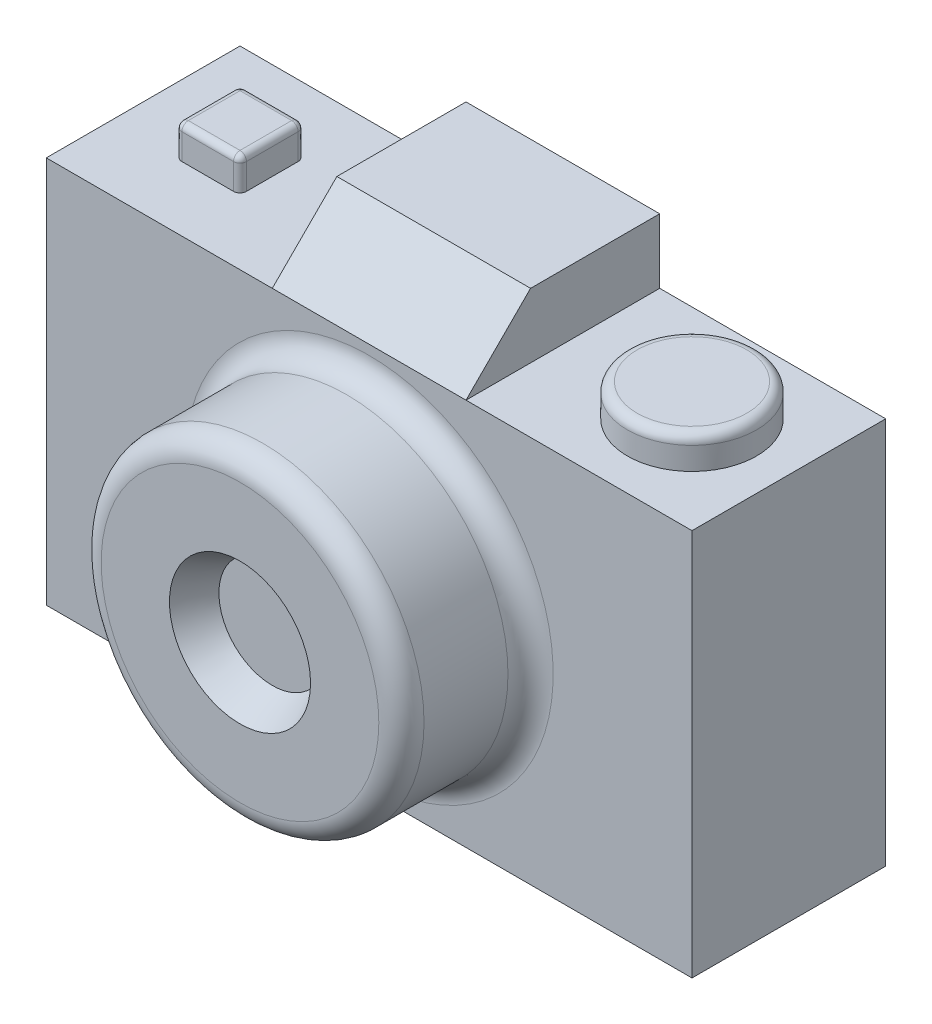
from build123d import *

# Parameters (mm, degrees)
SKETCH1_W           = 100
SKETCH1_H           = 30
BOSS_EXTRUDE1_DEPTH = 60
SKETCH2_R           = 25
BOSS_EXTRUDE2_DEPTH = 20
SKETCH3_R           = 10
SKETCH3_W           = 10
SKETCH3_H           = 10
BOSS_EXTRUDE3_DEPTH = 5
SKETCH4_W           = 30
SKETCH4_H           = 30
BOSS_EXTRUDE4_DEPTH = 10
CHAMFER1_SIZE       = 10
FILLET1_R           = 1
FILLET2_R           = 1.5
FILLET3_R           = 3.5
SKETCH5_R           = 10.925128043
CUT_EXTRUDE1_DEPTH  = 5
CUT_EXTRUDE1_TAPER  = 28


with BuildPart() as part:
    # Sketch1 → Boss-Extrude1 (new body)
    with BuildSketch(Plane(origin=(0, 0, 0), x_dir=(1, 0, 0), z_dir=(0, 1, 0))):
        with Locations((50, 15)):
            Rectangle(SKETCH1_W, SKETCH1_H)
    extrude(amount=BOSS_EXTRUDE1_DEPTH)

    # Sketch2 → Boss-Extrude2 (add)
    with BuildSketch(Plane.XY):
        with Locations((50, 30)):
            Circle(SKETCH2_R)
    extrude(amount=BOSS_EXTRUDE2_DEPTH)

    # Sketch3 → Boss-Extrude3 (add)
    with BuildSketch(Plane(origin=(0, 60, 0), x_dir=(1, 0, 0), z_dir=(0, 1, 0))):
        with Locations((85, 15)):
            Circle(SKETCH3_R)
        with Locations((15, 15)):
            Rectangle(SKETCH3_W, SKETCH3_H)
    extrude(amount=BOSS_EXTRUDE3_DEPTH)

    # Sketch4 → Boss-Extrude4 (add)
    with BuildSketch(Plane(origin=(0, 60, 0), x_dir=(1, 0, 0), z_dir=(0, 1, 0))):
        with Locations((50, 15)):
            Rectangle(SKETCH4_W, SKETCH4_H)
    extrude(amount=BOSS_EXTRUDE4_DEPTH)

    # Chamfer1
    chamfer1_edges = [part.edges().sort_by_distance(p)[0] for p in [
        (50, 70, 0),
    ]]
    chamfer(chamfer1_edges, length=CHAMFER1_SIZE)

    # Fillet1
    fillet1_edges = [part.edges().sort_by_distance(p)[0] for p in [
        (20, 62.5, -10),
        (20, 62.5, -20),
        (10, 62.5, -20),
        (10, 62.5, -10),
        (20, 65, -15),
        (15, 65, -20),
        (10, 65, -15),
        (15, 65, -10),
    ]]
    fillet(fillet1_edges, radius=FILLET1_R)

    # Fillet2
    fillet2_edges = [part.edges().sort_by_distance(p)[0] for p in [
        (75, 65, -15),
    ]]
    fillet(fillet2_edges, radius=FILLET2_R)

    # Fillet3
    fillet3_edges = [part.edges().sort_by_distance(p)[0] for p in [
        (25, 30, 0),
        (25, 30, 20),
    ]]
    fillet(fillet3_edges, radius=FILLET3_R)

    # Sketch5 → Cut-Extrude1 (cut)
    with BuildSketch(Plane.XY.offset(20)):
        with Locations((50, 30)):
            Circle(SKETCH5_R)
    extrude(amount=-CUT_EXTRUDE1_DEPTH, taper=CUT_EXTRUDE1_TAPER, mode=Mode.SUBTRACT)


solid = part.part
